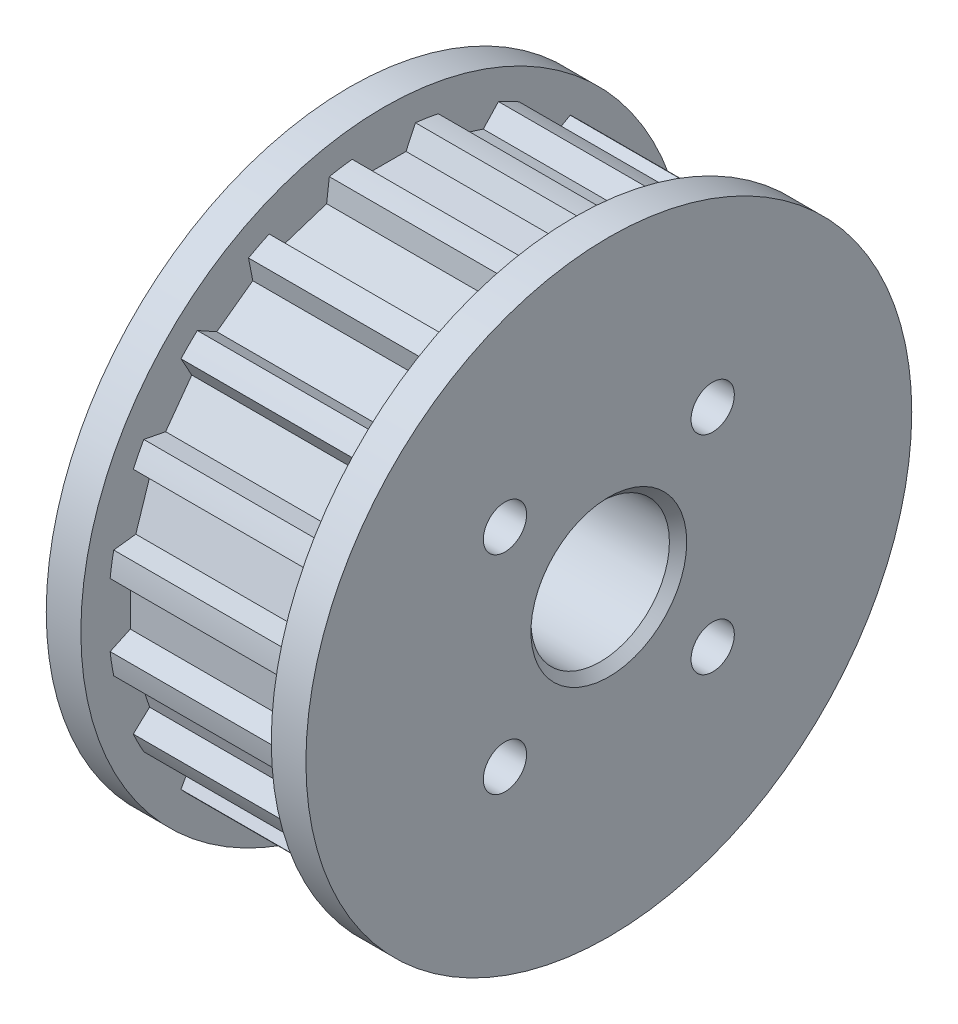
from build123d import *

# Parameters (mm, degrees)
SKETCH_1_R             = 4
EXTRUDE_1_DEPTH        = 11
SKETCH_2_R             = 17.5
SKETCH_2_R_2           = 4
EXTRUDE_2_DEPTH        = 2
SKETCH_3_R             = 17.5
SKETCH_3_R_2           = 4
EXTRUDE_3_DEPTH        = 2
CHAMFER_1_SIZE         = 0.5
HOLE_WIZARD_M3_1_D     = 2.5
HOLE_WIZARD_M3_1_DEPTH = 5
HOLE_WIZARD_M3_1_TIP   = 0.751075774
HOLE_WIZARD_M3_2_D     = 2.5
HOLE_WIZARD_M3_2_DEPTH = 5
HOLE_WIZARD_M3_2_TIP   = 0.751075774


with BuildPart() as part:
    # 草图1 → 凸台-拉伸1 (new body)
    with BuildSketch(Plane(origin=(0, 0, 0), x_dir=(0, 0, -1), z_dir=(1, 0, 0))):
        with BuildLine():
            Line((-1.285, 14.645), (1.285, 14.645))
            Line((1.285, 14.645), (1.828089361, 15.809658892))
            ThreePointArc((1.828089361, 15.809658892), (2.489654511, 15.719059941), (3.146836974, 15.60078979))
            Line((3.146836974, 15.60078979), (3.303446259, 14.325309519))
            Line((3.303446259, 14.325309519), (5.747661506, 13.531135843))
            Line((5.747661506, 13.531135843), (6.624069572, 14.47096843))
            ThreePointArc((6.624069572, 14.47096843), (7.225258803, 14.180368832), (7.813728981, 13.864806685))
            Line((7.813728981, 13.864806685), (7.568528182, 12.603357932))
            Line((7.568528182, 12.603357932), (9.647701858, 11.092749833))
            Line((9.647701858, 11.092749833), (10.771639701, 11.715758753))
            ThreePointArc((10.771639701, 11.715758753), (11.253604423, 11.253604423), (11.715758753, 10.771639701))
            Line((11.715758753, 10.771639701), (11.092749833, 9.647701858))
            Line((11.092749833, 9.647701858), (12.603357932, 7.568528182))
            Line((12.603357932, 7.568528182), (13.864806685, 7.813728981))
            ThreePointArc((13.864806685, 7.813728981), (14.180368832, 7.225258803), (14.47096843, 6.624069572))
            Line((14.47096843, 6.624069572), (13.531135843, 5.747661506))
            Line((13.531135843, 5.747661506), (14.325309519, 3.303446259))
            Line((14.325309519, 3.303446259), (15.60078979, 3.146836974))
            ThreePointArc((15.60078979, 3.146836974), (15.719059941, 2.489654511), (15.809658892, 1.828089361))
            Line((15.809658892, 1.828089361), (14.645, 1.285))
            Line((14.645, 1.285), (14.645, -1.285))
            Line((14.645, -1.285), (15.809658892, -1.828089361))
            ThreePointArc((15.809658892, -1.828089361), (15.719059941, -2.489654511), (15.60078979, -3.146836974))
            Line((15.60078979, -3.146836974), (14.325309519, -3.303446259))
            Line((14.325309519, -3.303446259), (13.531135843, -5.747661506))
            Line((13.531135843, -5.747661506), (14.47096843, -6.624069572))
            ThreePointArc((14.47096843, -6.624069572), (14.180368832, -7.225258803), (13.864806685, -7.813728981))
            Line((13.864806685, -7.813728981), (12.603357932, -7.568528182))
            Line((12.603357932, -7.568528182), (11.092749833, -9.647701858))
            Line((11.092749833, -9.647701858), (11.715758753, -10.771639701))
            ThreePointArc((11.715758753, -10.771639701), (11.253604423, -11.253604423), (10.771639701, -11.715758753))
            Line((10.771639701, -11.715758753), (9.647701858, -11.092749833))
            Line((9.647701858, -11.092749833), (7.568528182, -12.603357932))
            Line((7.568528182, -12.603357932), (7.813728981, -13.864806685))
            ThreePointArc((7.813728981, -13.864806685), (7.225258803, -14.180368832), (6.624069572, -14.47096843))
            Line((6.624069572, -14.47096843), (5.747661506, -13.531135843))
            Line((5.747661506, -13.531135843), (3.303446259, -14.325309519))
            Line((3.303446259, -14.325309519), (3.146836974, -15.60078979))
            ThreePointArc((3.146836974, -15.60078979), (2.489654511, -15.719059941), (1.828089361, -15.809658892))
            Line((1.828089361, -15.809658892), (1.285, -14.645))
            Line((1.285, -14.645), (-1.285, -14.645))
            Line((-1.285, -14.645), (-1.828089361, -15.809658892))
            ThreePointArc((-1.828089361, -15.809658892), (-2.489654511, -15.719059941), (-3.146836974, -15.60078979))
            Line((-3.146836974, -15.60078979), (-3.303446259, -14.325309519))
            Line((-3.303446259, -14.325309519), (-5.747661506, -13.531135843))
            Line((-5.747661506, -13.531135843), (-6.624069572, -14.47096843))
            ThreePointArc((-6.624069572, -14.47096843), (-7.225258803, -14.180368832), (-7.813728981, -13.864806685))
            Line((-7.813728981, -13.864806685), (-7.568528182, -12.603357932))
            Line((-7.568528182, -12.603357932), (-9.647701858, -11.092749833))
            Line((-9.647701858, -11.092749833), (-10.771639701, -11.715758753))
            ThreePointArc((-10.771639701, -11.715758753), (-11.253604423, -11.253604423), (-11.715758753, -10.771639701))
            Line((-11.715758753, -10.771639701), (-11.092749833, -9.647701858))
            Line((-11.092749833, -9.647701858), (-12.603357932, -7.568528182))
            Line((-12.603357932, -7.568528182), (-13.864806685, -7.813728981))
            ThreePointArc((-13.864806685, -7.813728981), (-14.180368832, -7.225258803), (-14.47096843, -6.624069572))
            Line((-14.47096843, -6.624069572), (-13.531135843, -5.747661506))
            Line((-13.531135843, -5.747661506), (-14.325309519, -3.303446259))
            Line((-14.325309519, -3.303446259), (-15.60078979, -3.146836974))
            ThreePointArc((-15.60078979, -3.146836974), (-15.719059941, -2.489654511), (-15.809658892, -1.828089361))
            Line((-15.809658892, -1.828089361), (-14.645, -1.285))
            Line((-14.645, -1.285), (-14.645, 1.285))
            Line((-14.645, 1.285), (-15.809658892, 1.828089361))
            ThreePointArc((-15.809658892, 1.828089361), (-15.719059941, 2.489654511), (-15.60078979, 3.146836974))
            Line((-15.60078979, 3.146836974), (-14.325309519, 3.303446259))
            Line((-14.325309519, 3.303446259), (-13.531135843, 5.747661506))
            Line((-13.531135843, 5.747661506), (-14.47096843, 6.624069572))
            ThreePointArc((-14.47096843, 6.624069572), (-14.180368832, 7.225258803), (-13.864806685, 7.813728981))
            Line((-13.864806685, 7.813728981), (-12.603357932, 7.568528182))
            Line((-12.603357932, 7.568528182), (-11.092749833, 9.647701858))
            Line((-11.092749833, 9.647701858), (-11.715758753, 10.771639701))
            ThreePointArc((-11.715758753, 10.771639701), (-11.253604423, 11.253604423), (-10.771639701, 11.715758753))
            Line((-10.771639701, 11.715758753), (-9.647701858, 11.092749833))
            Line((-9.647701858, 11.092749833), (-7.568528182, 12.603357932))
            Line((-7.568528182, 12.603357932), (-7.813728981, 13.864806685))
            ThreePointArc((-7.813728981, 13.864806685), (-7.225258803, 14.180368832), (-6.624069572, 14.47096843))
            Line((-6.624069572, 14.47096843), (-5.747661506, 13.531135843))
            Line((-5.747661506, 13.531135843), (-3.303446259, 14.325309519))
            Line((-3.303446259, 14.325309519), (-3.146836974, 15.60078979))
            ThreePointArc((-3.146836974, 15.60078979), (-2.489654511, 15.719059941), (-1.828089361, 15.809658892))
            Line((-1.828089361, 15.809658892), (-1.285, 14.645))
        make_face()
        Circle(SKETCH_1_R, mode=Mode.SUBTRACT)
    extrude(amount=EXTRUDE_1_DEPTH)

    # 草图2 → 凸台-拉伸2 (add)
    with BuildSketch(Plane(origin=(11, 0, 0), x_dir=(0, 0, -1), z_dir=(1, 0, 0))):
        Circle(SKETCH_2_R)
        Circle(SKETCH_2_R_2, mode=Mode.SUBTRACT)
    extrude(amount=EXTRUDE_2_DEPTH)

    # 草图3 → 凸台-拉伸3 (add)
    with BuildSketch(Plane.ZY):
        Circle(SKETCH_3_R)
        Circle(SKETCH_3_R_2, mode=Mode.SUBTRACT)
    extrude(amount=EXTRUDE_3_DEPTH)

    # 倒角1
    chamfer_1_edges = [part.edges().sort_by_distance(p)[0] for p in [
        (13, 0, 4),
        (-2, 0, -4),
    ]]
    chamfer(chamfer_1_edges, length=CHAMFER_1_SIZE)

    # M3 螺纹孔1
    with Locations(Plane(origin=(13, 0, 0), x_dir=(0, 0, -1), z_dir=(1, 0, 0))):
        with Locations((-6, 6), (6, 6), (6, -6), (-6, -6)):
            Hole(HOLE_WIZARD_M3_1_D / 2, depth=HOLE_WIZARD_M3_1_DEPTH)
            with Locations((0, 0, -(HOLE_WIZARD_M3_1_DEPTH + HOLE_WIZARD_M3_1_TIP / 2))):  # 118° drill point
                Cone(0, HOLE_WIZARD_M3_1_D / 2, HOLE_WIZARD_M3_1_TIP, mode=Mode.SUBTRACT)

    # M3 螺纹孔2
    with Locations(Plane.ZY.offset(2)):
        with Locations((-6, 6), (6, 6), (6, -6), (-6, -6)):
            Hole(HOLE_WIZARD_M3_2_D / 2, depth=HOLE_WIZARD_M3_2_DEPTH)
            with Locations((0, 0, -(HOLE_WIZARD_M3_2_DEPTH + HOLE_WIZARD_M3_2_TIP / 2))):  # 118° drill point
                Cone(0, HOLE_WIZARD_M3_2_D / 2, HOLE_WIZARD_M3_2_TIP, mode=Mode.SUBTRACT)


solid = part.part
